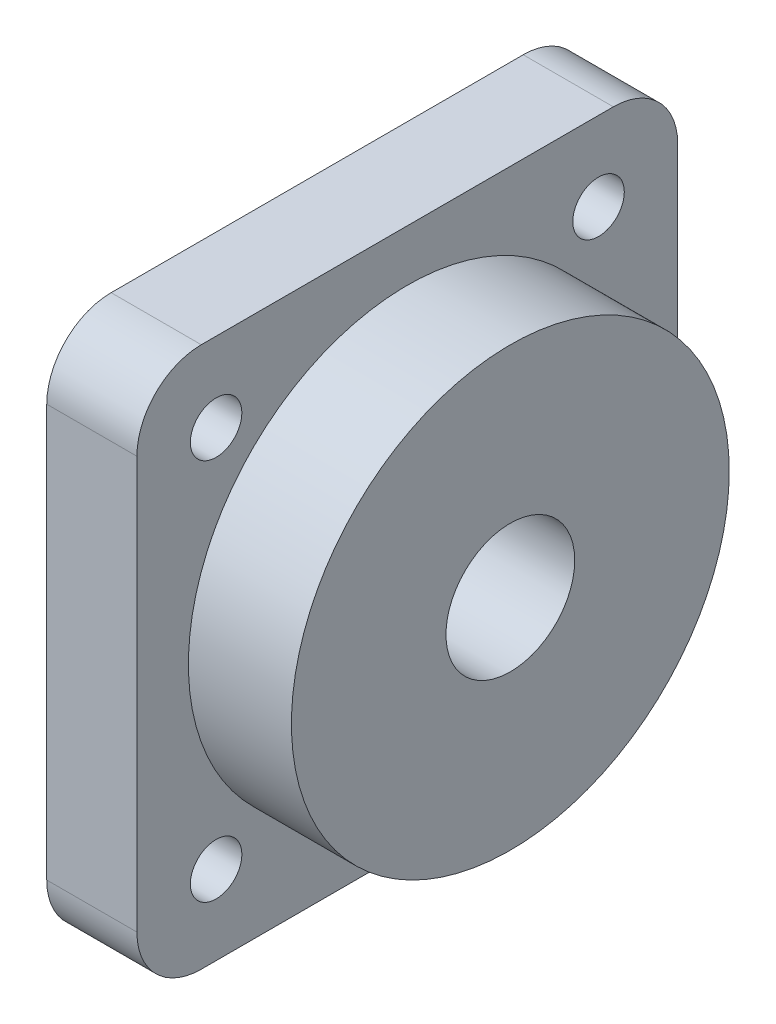
from build123d import *

# Parameters (mm, degrees)
SKETCH1_W           = 42
SKETCH1_H           = 42
SKETCH1_R           = 2
SKETCH1_R_2         = 10
BOSS_EXTRUDE1_DEPTH = 7
SKETCH2_R           = 17
SKETCH2_R_2         = 5
BOSS_EXTRUDE2_DEPTH = 15
FILLET1_R           = 5


with BuildPart() as part:
    # Sketch1 → Boss-Extrude1 (new body)
    with BuildSketch(Plane(origin=(0, 0, 0), x_dir=(0, 0, -1), z_dir=(1, 0, 0))):
        Rectangle(SKETCH1_W, SKETCH1_H)
        with Locations((-14.849242405, 14.849242405)):
            Circle(SKETCH1_R, mode=Mode.SUBTRACT)
        with Locations((14.849242405, 14.849242405)):
            Circle(SKETCH1_R, mode=Mode.SUBTRACT)
        with Locations((14.849242405, -14.849242405)):
            Circle(SKETCH1_R, mode=Mode.SUBTRACT)
        with Locations((-14.849242405, -14.849242405)):
            Circle(SKETCH1_R, mode=Mode.SUBTRACT)
        Circle(SKETCH1_R_2, mode=Mode.SUBTRACT)
    extrude(amount=BOSS_EXTRUDE1_DEPTH)

    # Sketch2 → Boss-Extrude2 (add)
    with BuildSketch(Plane(origin=(0, 0, 0), x_dir=(0, 0, -1), z_dir=(1, 0, 0))):
        Circle(SKETCH2_R)
        Circle(SKETCH2_R_2, mode=Mode.SUBTRACT)
    extrude(amount=BOSS_EXTRUDE2_DEPTH)

    # Fillet1
    fillet1_edges = [part.edges().sort_by_distance(p)[0] for p in [
        (3.5, 21, 21),
        (3.5, 21, -21),
        (3.5, -21, -21),
        (3.5, -21, 21),
    ]]
    fillet(fillet1_edges, radius=FILLET1_R)


solid = part.part
